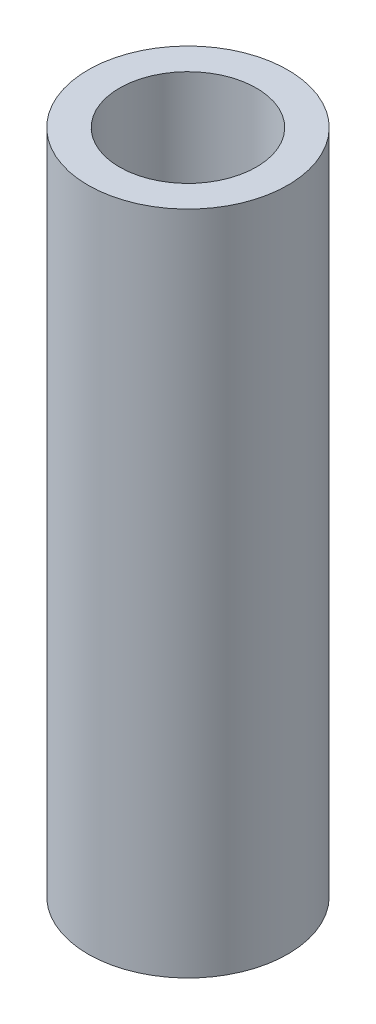
from build123d import *

# Parameters (mm, degrees)
SKETCH1_R                 = 2.38125
BOSS_EXTRUDE1_DEPTH       = 15.875
F_4_CLEARANCE_HOLE1_D     = 3.2639
F_4_CLEARANCE_HOLE1_DEPTH = 7.62
F_4_CLEARANCE_HOLE1_TIP   = 0.980574487


with BuildPart() as part:
    # Sketch1 → Boss-Extrude1 (new body)
    with BuildSketch(Plane(origin=(0, 0, 0), x_dir=(1, 0, 0), z_dir=(0, 1, 0))):
        Circle(SKETCH1_R)
    extrude(amount=BOSS_EXTRUDE1_DEPTH)

    # #4 Clearance Hole1
    with Locations(Plane(origin=(0, 15.875, 0), x_dir=(-1, 0, 0), z_dir=(0, 1, 0))):
        with Locations((0, 0)):
            Hole(F_4_CLEARANCE_HOLE1_D / 2, depth=F_4_CLEARANCE_HOLE1_DEPTH)
            with Locations((0, 0, -(F_4_CLEARANCE_HOLE1_DEPTH + F_4_CLEARANCE_HOLE1_TIP / 2))):  # 118° drill point
                Cone(0, F_4_CLEARANCE_HOLE1_D / 2, F_4_CLEARANCE_HOLE1_TIP, mode=Mode.SUBTRACT)


solid = part.part
